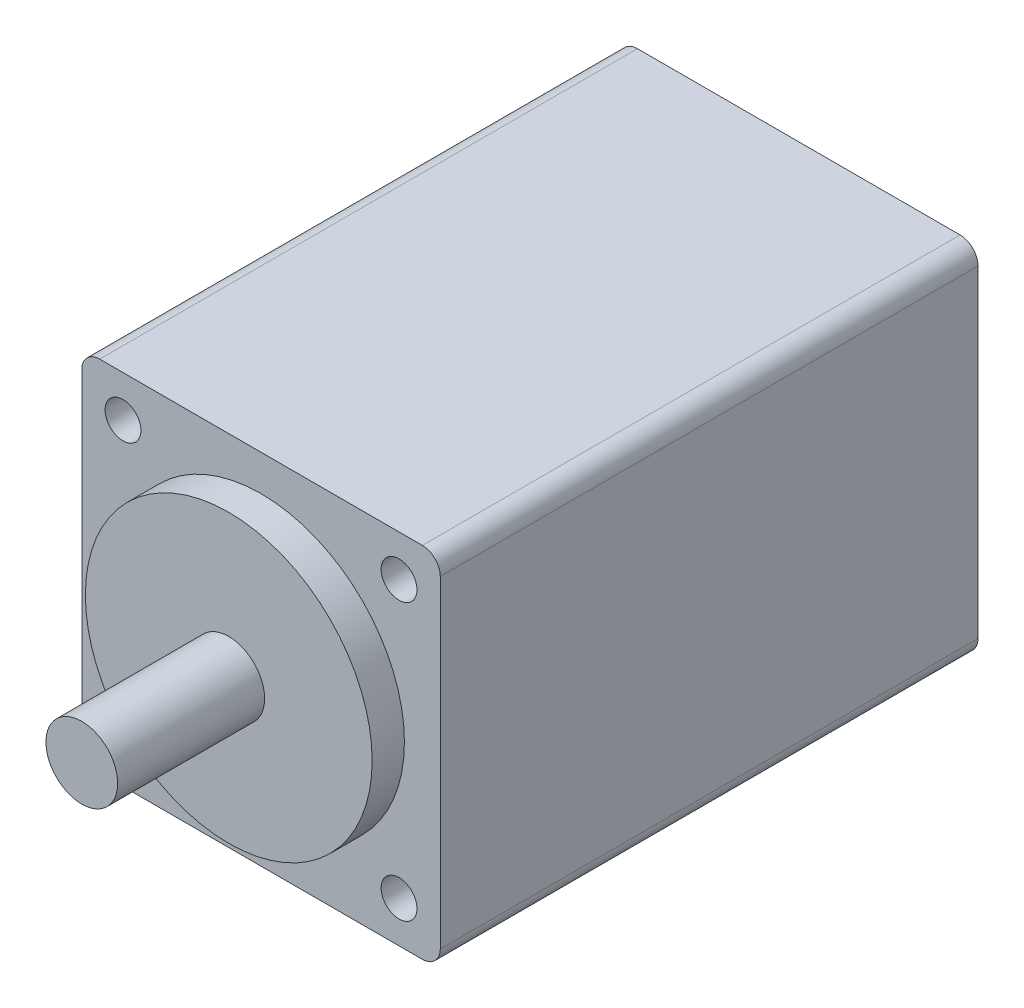
from build123d import *

# Parameters (mm, degrees)
SKETCH1_W           = 20
SKETCH1_H           = 20
BOSS_EXTRUDE1_DEPTH = 30
FILLET1_R           = 1
SKETCH2_R           = 8
BOSS_EXTRUDE2_DEPTH = 1.8
SKETCH3_R           = 2
BOSS_EXTRUDE3_DEPTH = 8.2
SKETCH4_R           = 1
CUT_EXTRUDE1_DEPTH  = 3


with BuildPart() as part:
    # Sketch1 → Boss-Extrude1 (new body)
    with BuildSketch(Plane.XY):
        Rectangle(SKETCH1_W, SKETCH1_H)
    extrude(amount=BOSS_EXTRUDE1_DEPTH)

    # Fillet1
    fillet1_edges = [part.edges().sort_by_distance(p)[0] for p in [
        (10, -10, 15),
        (-10, -10, 15),
        (-10, 10, 15),
        (10, 10, 15),
    ]]
    fillet(fillet1_edges, radius=FILLET1_R)

    # Sketch2 → Boss-Extrude2 (add)
    with BuildSketch(Plane.XY.offset(30)):
        Circle(SKETCH2_R)
    extrude(amount=BOSS_EXTRUDE2_DEPTH)

    # Sketch3 → Boss-Extrude3 (add)
    with BuildSketch(Plane.XY.offset(31.8)):
        Circle(SKETCH3_R)
    extrude(amount=BOSS_EXTRUDE3_DEPTH)

    # Sketch4 → Cut-Extrude1 (cut)
    with BuildSketch(Plane.XY.offset(30)):
        with Locations((-7.7, 7.7)):
            Circle(SKETCH4_R)
        with Locations((7.7, 7.7)):
            Circle(SKETCH4_R)
        with Locations((7.7, -7.7)):
            Circle(SKETCH4_R)
        with Locations((-7.7, -7.7)):
            Circle(SKETCH4_R)
    extrude(amount=-CUT_EXTRUDE1_DEPTH, mode=Mode.SUBTRACT)


solid = part.part
